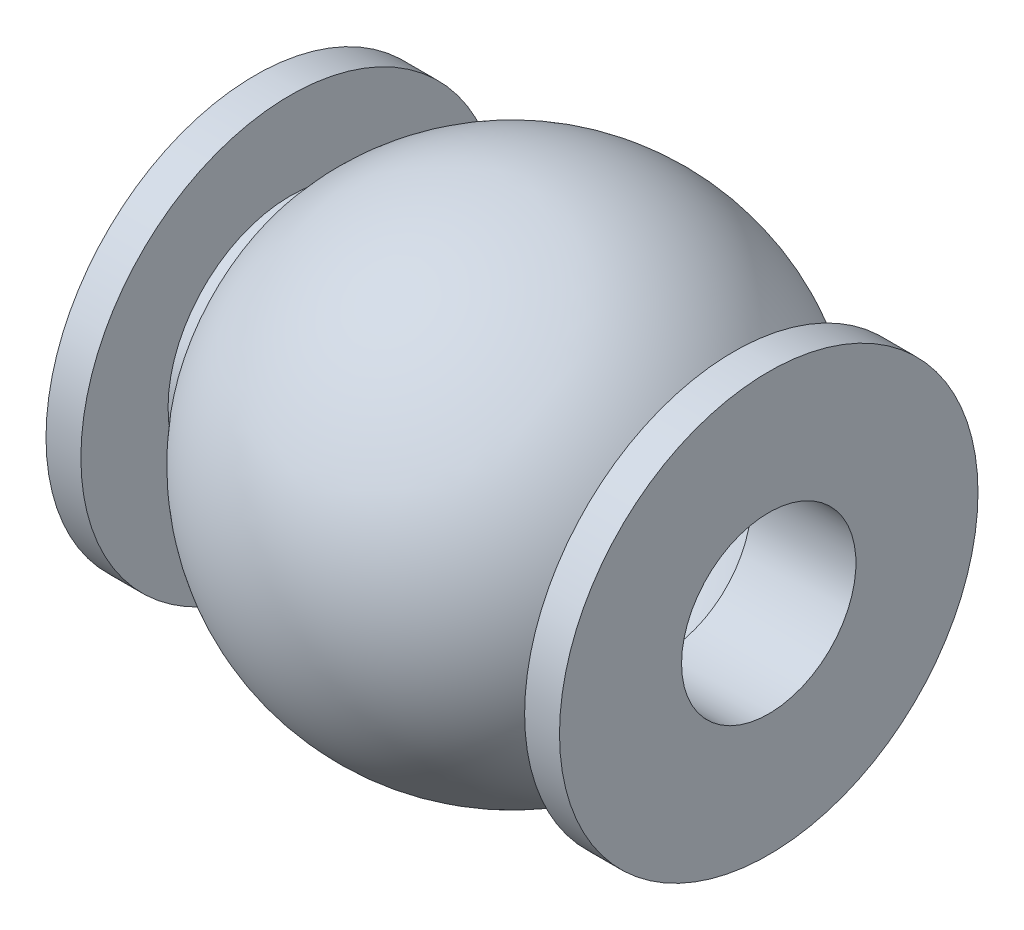
from build123d import *

# Parameters (mm, degrees)
SKETCH_2_R          = 2.5
CUT_EXTRUDE_1_DEPTH = 15.723805295


with BuildPart() as part:
    # Эскиз1 → Повернуть1 (revolve)
    with BuildSketch(Plane.XY):
        with BuildLine():
            Line((0, 0), (0, 6))
            Line((0, 6), (1, 6))
            Line((1, 6), (1, 3.5))
            Line((1, 3.5), (2, 3.5))
            Line((2, 3.5), (2, 4.5))
            ThreePointArc((2, 4.5), (7.361902647, 7), (12.723805295, 4.5))
            Line((12.723805295, 4.5), (12.723805295, 3.5))
            Line((12.723805295, 3.5), (13.723805295, 3.5))
            Line((13.723805295, 3.5), (13.723805295, 6))
            Line((13.723805295, 6), (14.723805295, 6))
            Line((14.723805295, 6), (14.723805295, 0))
            Line((14.723805295, 0), (11.723805295, 0))
            Line((11.723805295, 0), (11.723805295, 4.119927826))
            ThreePointArc((11.723805295, 4.119927826), (7.361902647, 6), (3, 4.119927826))
            Line((3, 4.119927826), (3, 0))
            Line((3, 0), (0, 0))
        make_face()
    revolve(axis=Axis((0, 0, 0), (1, 0, 0)))

    # Эскиз2 → Вырез-Вытянуть1 (cut, through all)
    with BuildSketch(Plane.ZY):
        Circle(SKETCH_2_R)
    extrude(amount=-CUT_EXTRUDE_1_DEPTH, mode=Mode.SUBTRACT)


solid = part.part
